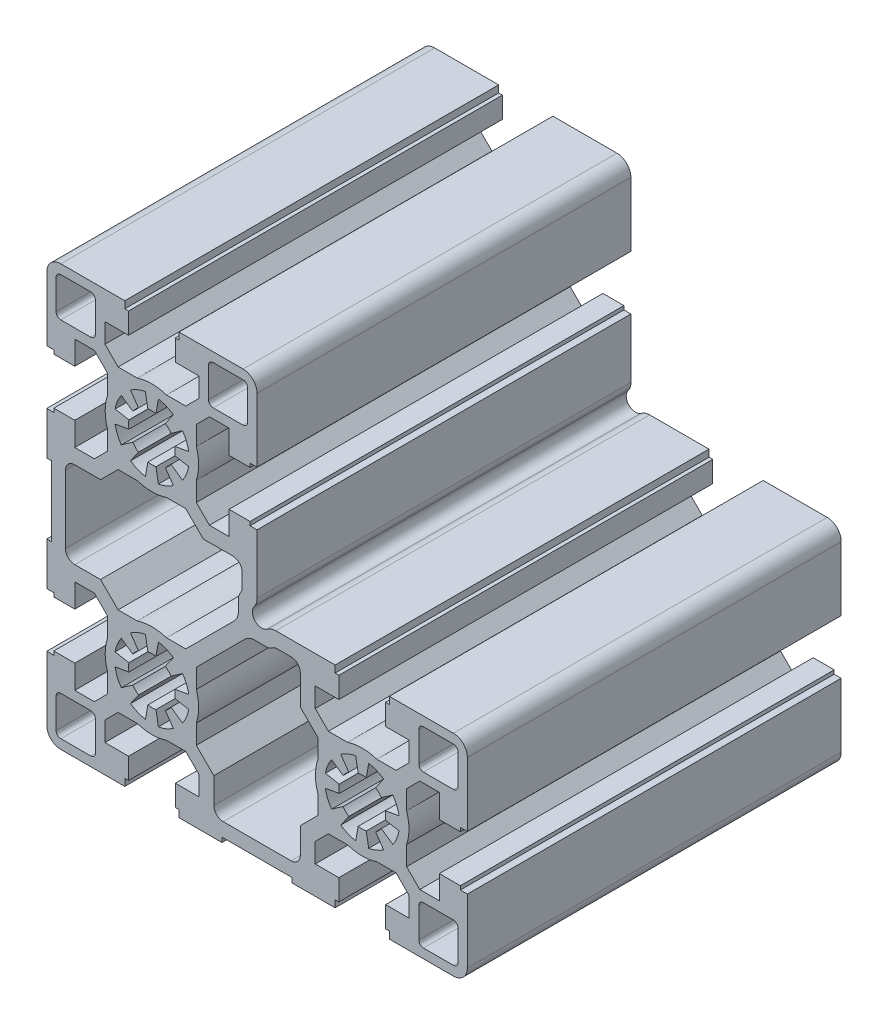
from build123d import *

# Parameters (mm, degrees)
EXTRUDE1_DEPTH = 80


with BuildPart() as part:
    # Sketch1 → Extrude1 (new body)
    with BuildSketch(Plane.XY):
        with BuildLine():
            Line((-81.826623631, 61.217840376), (-68.126623631, 61.217840376))
            Line((-68.126623631, 61.217840376), (-68.126623631, 59.717840379))
            Line((-68.126623631, 59.717840379), (-67.32662363, 59.717840379))
            Line((-67.32662363, 59.717840379), (-67.32662363, 55.217840379))
            Line((-67.32662363, 55.217840379), (-72.37662363, 55.217840379))
            Line((-72.37662363, 55.217840379), (-72.37662363, 51.030582079))
            Line((-72.37662363, 51.030582079), (-69.56388193, 48.217840379))
            Line((-69.56388193, 48.217840379), (-65.44912263, 48.217840379))
            ThreePointArc((-65.44912263, 48.217840379), (-62.32662363, 48.717840379), (-59.20412463, 48.217840379))
            Line((-59.20412463, 48.217840379), (-55.08936533, 48.217840379))
            Line((-55.08936533, 48.217840379), (-52.27662363, 51.030582079))
            Line((-52.27662363, 51.030582079), (-52.27662363, 55.217840379))
            Line((-52.27662363, 55.217840379), (-57.326623631, 55.217840379))
            Line((-57.326623631, 55.217840379), (-57.326623631, 59.717840379))
            Line((-57.326623631, 59.717840379), (-56.526623631, 59.717840379))
            Line((-56.526623631, 59.717840379), (-56.526623631, 61.217840376))
            Line((-56.526623631, 61.217840376), (-42.826623631, 61.217840376))
            ThreePointArc((-42.826623631, 61.217840376), (-40.705303287, 60.339160719), (-39.826623631, 58.217840376))
            Line((-39.826623631, 58.217840376), (-39.826623631, 44.517840379))
            Line((-39.826623631, 44.517840379), (-41.32662363, 44.517840379))
            Line((-41.32662363, 44.517840379), (-41.32662363, 43.717840379))
            Line((-41.32662363, 43.717840379), (-45.82662363, 43.717840379))
            Line((-45.82662363, 43.717840379), (-45.82662363, 48.767840379))
            Line((-45.82662363, 48.767840379), (-50.01388193, 48.767840379))
            Line((-50.01388193, 48.767840379), (-52.82662363, 45.955098679))
            Line((-52.82662363, 45.955098679), (-52.82662363, 41.840339379))
            ThreePointArc((-52.82662363, 41.840339379), (-52.326623629, 38.717840379), (-52.82662363, 35.595341379))
            Line((-52.82662363, 35.595341379), (-52.82662363, 31.480582079))
            Line((-52.82662363, 31.480582079), (-50.01388193, 28.667840379))
            Line((-50.01388193, 28.667840379), (-45.82662363, 28.667840379))
            Line((-45.82662363, 28.667840379), (-45.82662363, 33.717840379))
            Line((-45.82662363, 33.717840379), (-41.32662363, 33.717840379))
            Line((-41.32662363, 33.717840379), (-41.32662363, 32.917840379))
            Line((-41.32662363, 32.917840379), (-39.82662363, 32.917840379))
            Line((-39.82662363, 32.917840379), (-39.82662363, 20.221143989))
            ThreePointArc((-39.82662363, 20.221143989), (-39.982163304, 19.267705236), (-40.432653933, 18.413131519))
            ThreePointArc((-40.432653933, 18.413131519), (-40.250887698, 15.793576309), (-37.631332489, 15.611810073))
            ThreePointArc((-37.631332489, 15.611810073), (-36.776758772, 16.062300701), (-35.823320021, 16.217840375))
            Line((-35.823320021, 16.217840375), (-23.126623631, 16.217840375))
            Line((-23.126623631, 16.217840375), (-23.126623631, 14.717840372))
            Line((-23.126623631, 14.717840372), (-22.326623631, 14.717840372))
            Line((-22.326623631, 14.717840372), (-22.326623631, 10.217840395))
            Line((-22.326623631, 10.217840395), (-27.376623631, 10.217840395))
            Line((-27.376623631, 10.217840395), (-27.376623631, 6.030582095))
            Line((-27.376623631, 6.030582095), (-24.563881931, 3.217840395))
            Line((-24.563881931, 3.217840395), (-20.449122631, 3.217840395))
            ThreePointArc((-20.449122631, 3.217840395), (-17.326623631, 3.717840396), (-14.204124631, 3.217840395))
            Line((-14.204124631, 3.217840395), (-10.089365331, 3.217840395))
            Line((-10.089365331, 3.217840395), (-7.276623631, 6.030582095))
            Line((-7.276623631, 6.030582095), (-7.276623631, 10.217840376))
            Line((-7.276623631, 10.217840376), (-12.326623631, 10.217840376))
            Line((-12.326623631, 10.217840376), (-12.326623631, 14.717840376))
            Line((-12.326623631, 14.717840376), (-11.526623631, 14.717840376))
            Line((-11.526623631, 14.717840376), (-11.526623631, 16.217840376))
            Line((-11.526623631, 16.217840376), (2.173376369, 16.217840376))
            ThreePointArc((2.173376369, 16.217840376), (4.294696713, 15.339160719), (5.173376369, 13.217840376))
            Line((5.173376369, 13.217840376), (5.173376369, -0.482159605))
            Line((5.173376369, -0.482159605), (3.673376369, -0.482159605))
            Line((3.673376369, -0.482159605), (3.673376369, -1.282159605))
            Line((3.673376369, -1.282159605), (-0.826623631, -1.282159605))
            Line((-0.826623631, -1.282159605), (-0.826623631, 3.767840395))
            Line((-0.826623631, 3.767840395), (-5.013881931, 3.767840395))
            Line((-5.013881931, 3.767840395), (-7.826623631, 0.955098695))
            Line((-7.826623631, 0.955098695), (-7.826623631, -3.159660605))
            ThreePointArc((-7.826623631, -3.159660605), (-7.326623631, -6.282159605), (-7.826623631, -9.404658605))
            Line((-7.826623631, -9.404658605), (-7.826623631, -13.519417905))
            Line((-7.826623631, -13.519417905), (-5.013881931, -16.332159605))
            Line((-5.013881931, -16.332159605), (-0.826623631, -16.332159605))
            Line((-0.826623631, -16.332159605), (-0.826623631, -11.282159605))
            Line((-0.826623631, -11.282159605), (3.673376369, -11.282159605))
            Line((3.673376369, -11.282159605), (3.673376369, -12.082159605))
            Line((3.673376369, -12.082159605), (5.173376369, -12.082159605))
            Line((5.173376369, -12.082159605), (5.173376369, -25.782159624))
            ThreePointArc((5.173376369, -25.782159624), (4.294696713, -27.903479968), (2.173376369, -28.782159624))
            Line((2.173376369, -28.782159624), (-11.526623631, -28.782159624))
            Line((-11.526623631, -28.782159624), (-11.526623631, -27.282159624))
            Line((-11.526623631, -27.282159624), (-12.326623631, -27.282159624))
            Line((-12.326623631, -27.282159624), (-12.326623631, -22.782159624))
            Line((-12.326623631, -22.782159624), (-7.276623631, -22.782159624))
            Line((-7.276623631, -22.782159624), (-7.276623631, -18.594901305))
            Line((-7.276623631, -18.594901305), (-10.089365331, -15.782159605))
            Line((-10.089365331, -15.782159605), (-14.204124631, -15.782159605))
            ThreePointArc((-14.204124631, -15.782159605), (-17.326623631, -16.282159605), (-20.449122631, -15.782159605))
            Line((-20.449122631, -15.782159605), (-24.563881931, -15.782159605))
            Line((-24.563881931, -15.782159605), (-27.376623631, -18.594901305))
            Line((-27.376623631, -18.594901305), (-27.376623631, -22.782159605))
            Line((-27.376623631, -22.782159605), (-22.32662363, -22.782159605))
            Line((-22.32662363, -22.782159605), (-22.32662363, -27.282159627))
            Line((-22.32662363, -27.282159627), (-23.12662363, -27.282159627))
            Line((-23.12662363, -27.282159627), (-23.12662363, -28.782159627))
            Line((-23.12662363, -28.782159627), (-32.32662363, -28.782159627))
            Line((-32.32662363, -28.782159627), (-32.32662363, -27.782159627))
            Line((-32.32662363, -27.782159627), (-47.32662363, -27.782159627))
            Line((-47.32662363, -27.782159627), (-47.32662363, -28.782159627))
            Line((-47.32662363, -28.782159627), (-56.52662363, -28.782159627))
            Line((-56.52662363, -28.782159627), (-56.52662363, -27.282159627))
            Line((-56.52662363, -27.282159627), (-57.32662363, -27.282159627))
            Line((-57.32662363, -27.282159627), (-57.32662363, -22.782159627))
            Line((-57.32662363, -22.782159627), (-52.27662363, -22.782159627))
            Line((-52.27662363, -22.782159627), (-52.27662363, -18.594901327))
            Line((-52.27662363, -18.594901327), (-55.08936533, -15.782159627))
            Line((-55.08936533, -15.782159627), (-59.20412463, -15.782159627))
            ThreePointArc((-59.20412463, -15.782159627), (-62.32662363, -16.282159628), (-65.44912263, -15.782159627))
            Line((-65.44912263, -15.782159627), (-69.56388193, -15.782159627))
            Line((-69.56388193, -15.782159627), (-72.37662363, -18.594901327))
            Line((-72.37662363, -18.594901327), (-72.37662363, -22.782159627))
            Line((-72.37662363, -22.782159627), (-67.326623631, -22.782159627))
            Line((-67.326623631, -22.782159627), (-67.326623631, -27.282159624))
            Line((-67.326623631, -27.282159624), (-68.126623631, -27.282159624))
            Line((-68.126623631, -27.282159624), (-68.126623631, -28.782159624))
            Line((-68.126623631, -28.782159624), (-81.826623631, -28.782159624))
            ThreePointArc((-81.826623631, -28.782159624), (-83.947943974, -27.903479968), (-84.826623631, -25.782159624))
            Line((-84.826623631, -25.782159624), (-84.826623631, -12.082159624))
            Line((-84.826623631, -12.082159624), (-83.326623631, -12.082159624))
            Line((-83.326623631, -12.082159624), (-83.326623631, -11.282159624))
            Line((-83.326623631, -11.282159624), (-78.82662363, -11.282159624))
            Line((-78.82662363, -11.282159624), (-78.82662363, -16.332159627))
            Line((-78.82662363, -16.332159627), (-74.63936533, -16.332159627))
            Line((-74.63936533, -16.332159627), (-71.82662363, -13.519417927))
            Line((-71.82662363, -13.519417927), (-71.82662363, -9.404658627))
            ThreePointArc((-71.82662363, -9.404658627), (-72.32662363, -6.282159627), (-71.82662363, -3.159660627))
            Line((-71.82662363, -3.159660627), (-71.82662363, 0.955098673))
            Line((-71.82662363, 0.955098673), (-74.63936533, 3.767840373))
            Line((-74.63936533, 3.767840373), (-78.82662363, 3.767840373))
            Line((-78.82662363, 3.767840373), (-78.82662363, -1.282159627))
            Line((-78.82662363, -1.282159627), (-83.32662363, -1.282159627))
            Line((-83.32662363, -1.282159627), (-83.32662363, -0.482159627))
            Line((-83.32662363, -0.482159627), (-84.82662363, -0.482159627))
            Line((-84.82662363, -0.482159627), (-84.82662363, 8.717840373))
            Line((-84.82662363, 8.717840373), (-83.82662363, 8.717840373))
            Line((-83.82662363, 8.717840373), (-83.82662363, 23.717840373))
            Line((-83.82662363, 23.717840373), (-84.82662363, 23.717840373))
            Line((-84.82662363, 23.717840373), (-84.82662363, 32.917840373))
            Line((-84.82662363, 32.917840373), (-83.32662363, 32.917840373))
            Line((-83.32662363, 32.917840373), (-83.32662363, 33.717840373))
            Line((-83.32662363, 33.717840373), (-78.82662363, 33.717840373))
            Line((-78.82662363, 33.717840373), (-78.82662363, 28.667840379))
            Line((-78.82662363, 28.667840379), (-74.63936533, 28.667840379))
            Line((-74.63936533, 28.667840379), (-71.82662363, 31.480582079))
            Line((-71.82662363, 31.480582079), (-71.82662363, 35.595341379))
            ThreePointArc((-71.82662363, 35.595341379), (-72.32662363, 38.717840379), (-71.82662363, 41.840339379))
            Line((-71.82662363, 41.840339379), (-71.82662363, 45.955098679))
            Line((-71.82662363, 45.955098679), (-74.63936533, 48.767840379))
            Line((-74.63936533, 48.767840379), (-78.826623631, 48.767840379))
            Line((-78.826623631, 48.767840379), (-78.826623631, 43.717840376))
            Line((-78.826623631, 43.717840376), (-83.326623631, 43.717840376))
            Line((-83.326623631, 43.717840376), (-83.326623631, 44.517840376))
            Line((-83.326623631, 44.517840376), (-84.826623631, 44.517840376))
            Line((-84.826623631, 44.517840376), (-84.826623631, 58.217840376))
            ThreePointArc((-84.826623631, 58.217840376), (-83.947943974, 60.339160719), (-81.826623631, 61.217840376))
        make_face()
        with BuildLine():
            Line((3.173376369, -19.382159624), (3.173376369, -25.782159624))
            ThreePointArc((3.173376369, -25.782159624), (2.880483151, -26.489266406), (2.173376369, -26.782159624))
            Line((2.173376369, -26.782159624), (-4.226623631, -26.782159624))
            ThreePointArc((-4.226623631, -26.782159624), (-4.933730412, -26.489266406), (-5.226623631, -25.782159624))
            Line((-5.226623631, -25.782159624), (-5.226623631, -19.382159624))
            ThreePointArc((-5.226623631, -19.382159624), (-4.933730412, -18.675052843), (-4.226623631, -18.382159624))
            Line((-4.226623631, -18.382159624), (2.173376369, -18.382159624))
            ThreePointArc((2.173376369, -18.382159624), (2.880483151, -18.675052843), (3.173376369, -19.382159624))
        make_face(mode=Mode.SUBTRACT)
        with BuildLine():
            Line((-36.920667716, 12.481354098), (-36.442965741, 12.754326662))
            ThreePointArc((-36.442965741, 12.754326662), (-35.96402373, 12.95083968), (-35.450687854, 13.017840384))
            Line((-35.450687854, 13.017840384), (-32.577053934, 13.017840384))
            ThreePointArc((-32.577053934, 13.017840384), (-31.162840372, 12.432053946), (-30.577053935, 11.017840384))
            Line((-30.577053935, 11.017840384), (-30.577053935, 4.705528984))
            Line((-30.577053935, 4.705528984), (-26.826623635, 0.955098684))
            Line((-26.826623635, 0.955098684), (-26.826623635, -3.159660616))
            ThreePointArc((-26.826623635, -3.159660616), (-27.326623632, -6.282159618), (-26.826623627, -9.404658618))
            Line((-26.826623627, -9.404658618), (-26.826623627, -13.519417918))
            Line((-26.826623627, -13.519417918), (-30.577053927, -17.269848218))
            Line((-30.577053927, -17.269848218), (-30.577053927, -22.782159618))
            ThreePointArc((-30.577053927, -22.782159618), (-31.162840364, -24.196373181), (-32.577053927, -24.782159618))
            Line((-32.577053927, -24.782159618), (-47.076623627, -24.782159618))
            ThreePointArc((-47.076623627, -24.782159618), (-48.490837189, -24.196373181), (-49.076623627, -22.782159618))
            Line((-49.076623627, -22.782159618), (-49.076623627, -17.269417918))
            Line((-49.076623627, -17.269417918), (-52.826623627, -13.519417918))
            Line((-52.826623627, -13.519417918), (-52.826623627, -9.404658618))
            ThreePointArc((-52.826623627, -9.404658618), (-52.326623629, -6.282159618), (-52.826623633, -3.159660618))
            Line((-52.826623633, -3.159660618), (-52.826623633, 0.955098682))
            Line((-52.826623633, 0.955098682), (-42.442561593, 11.339160722))
            ThreePointArc((-42.442561593, 11.339160722), (-41.469291546, 11.989478975), (-40.321241249, 12.217840376))
            Line((-40.321241249, 12.217840376), (-37.912945604, 12.217840376))
            ThreePointArc((-37.912945604, 12.217840376), (-37.399609728, 12.28484108), (-36.920667716, 12.481354098))
        make_face(mode=Mode.SUBTRACT)
        with BuildLine():
            Line((-18.715809051, 1.596302416), (-18.194864521, -1.358120845))
            ThreePointArc((-18.194864521, -1.358120845), (-17.326623631, -1.282159609), (-16.458382741, -1.358120845))
            Line((-16.458382741, -1.358120845), (-15.937438211, 1.596302415))
            ThreePointArc((-15.937438211, 1.596302415), (-14.265156173, 1.108876651), (-12.738012141, 0.271056745))
            Line((-12.738012141, 0.271056745), (-14.458741451, -2.186399385))
            ThreePointArc((-14.458741451, -2.186399385), (-13.791089727, -2.7466257), (-13.230863411, -3.414277425))
            Line((-13.230863411, -3.414277425), (-10.773407281, -1.693548115))
            ThreePointArc((-10.773407281, -1.693548115), (-9.935587375, -3.220692147), (-9.448161611, -4.892974184))
            Line((-9.448161611, -4.892974184), (-12.402584871, -5.413918715))
            ThreePointArc((-12.402584871, -5.413918715), (-12.326623636, -6.282159605), (-12.402584871, -7.150400495))
            Line((-12.402584871, -7.150400495), (-9.448161611, -7.671345025))
            ThreePointArc((-9.448161611, -7.671345025), (-9.935587375, -9.343627062), (-10.773407281, -10.870771094))
            Line((-10.773407281, -10.870771094), (-13.230863411, -9.150041785))
            ThreePointArc((-13.230863411, -9.150041785), (-13.791089727, -9.817693509), (-14.458741451, -10.377919825))
            Line((-14.458741451, -10.377919825), (-12.738012141, -12.835375955))
            ThreePointArc((-12.738012141, -12.835375955), (-14.265156173, -13.673195861), (-15.937438211, -14.160621625))
            Line((-15.937438211, -14.160621625), (-16.458382741, -11.206198365))
            ThreePointArc((-16.458382741, -11.206198365), (-17.326623631, -11.2821596), (-18.194864521, -11.206198365))
            Line((-18.194864521, -11.206198365), (-18.715809051, -14.160621625))
            ThreePointArc((-18.715809051, -14.160621625), (-20.388091089, -13.67319586), (-21.915235121, -12.835375954))
            Line((-21.915235121, -12.835375954), (-20.194505811, -10.377919825))
            ThreePointArc((-20.194505811, -10.377919825), (-20.862157536, -9.817693509), (-21.422383851, -9.150041785))
            Line((-21.422383851, -9.150041785), (-23.879839981, -10.870771095))
            ThreePointArc((-23.879839981, -10.870771095), (-24.717659887, -9.343627062), (-25.205085652, -7.671345025))
            Line((-25.205085652, -7.671345025), (-22.250662391, -7.150400495))
            ThreePointArc((-22.250662391, -7.150400495), (-22.326623627, -6.282159605), (-22.250662391, -5.413918715))
            Line((-22.250662391, -5.413918715), (-25.205085651, -4.892974185))
            ThreePointArc((-25.205085651, -4.892974185), (-24.717659887, -3.220692147), (-23.879839981, -1.693548115))
            Line((-23.879839981, -1.693548115), (-21.422383851, -3.414277425))
            ThreePointArc((-21.422383851, -3.414277425), (-20.862157536, -2.7466257), (-20.194505811, -2.186399385))
            Line((-20.194505811, -2.186399385), (-21.915235121, 0.271056745))
            ThreePointArc((-21.915235121, 0.271056745), (-20.388091089, 1.108876652), (-18.715809051, 1.596302416))
        make_face(mode=Mode.SUBTRACT)
        with BuildLine():
            Line((-4.226623631, 14.217840376), (2.173376369, 14.217840376))
            ThreePointArc((2.173376369, 14.217840376), (2.880483151, 13.924947157), (3.173376369, 13.217840376))
            Line((3.173376369, 13.217840376), (3.173376369, 6.817840376))
            ThreePointArc((3.173376369, 6.817840376), (2.880483151, 6.110733594), (2.173376369, 5.817840376))
            Line((2.173376369, 5.817840376), (-4.226623631, 5.817840376))
            ThreePointArc((-4.226623631, 5.817840376), (-4.933730412, 6.110733594), (-5.226623631, 6.817840376))
            Line((-5.226623631, 6.817840376), (-5.226623631, 13.217840376))
            ThreePointArc((-5.226623631, 13.217840376), (-4.933730412, 13.924947157), (-4.226623631, 14.217840376))
        make_face(mode=Mode.SUBTRACT)
        with BuildLine():
            Line((-42.826623631, 50.817840376), (-49.226623631, 50.817840376))
            ThreePointArc((-49.226623631, 50.817840376), (-49.933730412, 51.110733594), (-50.226623631, 51.817840376))
            Line((-50.226623631, 51.817840376), (-50.226623631, 58.217840376))
            ThreePointArc((-50.226623631, 58.217840376), (-49.933730412, 58.924947157), (-49.226623631, 59.217840376))
            Line((-49.226623631, 59.217840376), (-42.826623631, 59.217840376))
            ThreePointArc((-42.826623631, 59.217840376), (-42.119516849, 58.924947157), (-41.826623631, 58.217840376))
            Line((-41.826623631, 58.217840376), (-41.826623631, 51.817840376))
            ThreePointArc((-41.826623631, 51.817840376), (-42.119516849, 51.110733594), (-42.826623631, 50.817840376))
        make_face(mode=Mode.SUBTRACT)
        with BuildLine():
            Line((-63.71580905, 46.596302399), (-63.19486452, 43.641879139))
            ThreePointArc((-63.19486452, 43.641879139), (-62.32662363, 43.717840374), (-61.45838274, 43.641879139))
            Line((-61.45838274, 43.641879139), (-60.93743821, 46.596302399))
            ThreePointArc((-60.93743821, 46.596302399), (-59.265156172, 46.108876634), (-57.73801214, 45.271056728))
            Line((-57.73801214, 45.271056728), (-59.45874145, 42.813600599))
            ThreePointArc((-59.45874145, 42.813600599), (-58.791089725, 42.253374283), (-58.23086341, 41.585722559))
            Line((-58.23086341, 41.585722559), (-55.77340728, 43.306451869))
            ThreePointArc((-55.77340728, 43.306451869), (-54.935587374, 41.779307837), (-54.448161609, 40.107025799))
            Line((-54.448161609, 40.107025799), (-57.40258487, 39.586081269))
            ThreePointArc((-57.40258487, 39.586081269), (-57.326623634, 38.717840379), (-57.40258487, 37.849599489))
            Line((-57.40258487, 37.849599489), (-54.44816161, 37.328654959))
            ThreePointArc((-54.44816161, 37.328654959), (-54.935587374, 35.656372921), (-55.77340728, 34.129228889))
            Line((-55.77340728, 34.129228889), (-58.23086341, 35.849958199))
            ThreePointArc((-58.23086341, 35.849958199), (-58.791089725, 35.182306474), (-59.45874145, 34.622080159))
            Line((-59.45874145, 34.622080159), (-57.73801214, 32.164624029))
            ThreePointArc((-57.73801214, 32.164624029), (-59.265156172, 31.326804122), (-60.93743821, 30.839378358))
            Line((-60.93743821, 30.839378358), (-61.45838274, 33.793801619))
            ThreePointArc((-61.45838274, 33.793801619), (-62.32662363, 33.717840383), (-63.19486452, 33.793801619))
            Line((-63.19486452, 33.793801619), (-63.71580905, 30.839378359))
            ThreePointArc((-63.71580905, 30.839378359), (-65.388091088, 31.326804123), (-66.91523512, 32.164624029))
            Line((-66.91523512, 32.164624029), (-65.19450581, 34.622080159))
            ThreePointArc((-65.19450581, 34.622080159), (-65.862157534, 35.182306474), (-66.42238385, 35.849958199))
            Line((-66.42238385, 35.849958199), (-68.87983998, 34.129228889))
            ThreePointArc((-68.87983998, 34.129228889), (-69.717659886, 35.656372921), (-70.20508565, 37.328654959))
            Line((-70.20508565, 37.328654959), (-67.25066239, 37.849599489))
            ThreePointArc((-67.25066239, 37.849599489), (-67.326623625, 38.717840379), (-67.25066239, 39.586081269))
            Line((-67.25066239, 39.586081269), (-70.20508565, 40.107025799))
            ThreePointArc((-70.20508565, 40.107025799), (-69.717659886, 41.779307836), (-68.879839979, 43.306451868))
            Line((-68.879839979, 43.306451868), (-66.42238385, 41.585722559))
            ThreePointArc((-66.42238385, 41.585722559), (-65.862157534, 42.253374283), (-65.19450581, 42.813600599))
            Line((-65.19450581, 42.813600599), (-66.91523512, 45.271056729))
            ThreePointArc((-66.91523512, 45.271056729), (-65.388091088, 46.108876635), (-63.71580905, 46.596302399))
        make_face(mode=Mode.SUBTRACT)
        with BuildLine():
            Line((-44.705303281, 13.60190241), (-55.089365321, 3.21784037))
            Line((-55.089365321, 3.21784037), (-59.204124621, 3.21784037))
            ThreePointArc((-59.204124621, 3.21784037), (-62.32662362, 3.717840373), (-65.449122621, 3.217840376))
            Line((-65.449122621, 3.217840376), (-69.563881921, 3.217840376))
            Line((-69.563881921, 3.217840376), (-73.313881921, 6.967840376))
            Line((-73.313881921, 6.967840376), (-78.826623621, 6.967840376))
            ThreePointArc((-78.826623621, 6.967840376), (-80.240837183, 7.553626813), (-80.826623621, 8.967840376))
            Line((-80.826623621, 8.967840376), (-80.826623621, 23.467410076))
            ThreePointArc((-80.826623621, 23.467410076), (-80.240837183, 24.881623638), (-78.826623621, 25.467410076))
            Line((-78.826623621, 25.467410076), (-73.314312221, 25.467410076))
            Line((-73.314312221, 25.467410076), (-69.563881921, 29.217840376))
            Line((-69.563881921, 29.217840376), (-65.449122621, 29.217840376))
            ThreePointArc((-65.449122621, 29.217840376), (-62.32662362, 28.717840378), (-59.204124621, 29.217840382))
            Line((-59.204124621, 29.217840382), (-55.089365321, 29.217840382))
            Line((-55.089365321, 29.217840382), (-51.338935021, 25.467410082))
            Line((-51.338935021, 25.467410082), (-45.026623621, 25.467410082))
            ThreePointArc((-45.026623621, 25.467410082), (-43.612410058, 24.881623644), (-43.026623621, 23.467410082))
            Line((-43.026623621, 23.467410082), (-43.026623621, 20.593776162))
            ThreePointArc((-43.026623621, 20.593776162), (-43.093624325, 20.080440285), (-43.290137343, 19.601498274))
            Line((-43.290137343, 19.601498274), (-43.563109907, 19.123796299))
            ThreePointArc((-43.563109907, 19.123796299), (-43.759622925, 18.644854281), (-43.826623626, 18.131518399))
            Line((-43.826623626, 18.131518399), (-43.826623626, 15.723222749))
            ThreePointArc((-43.826623626, 15.723222749), (-44.054985028, 14.575172454), (-44.705303281, 13.60190241))
        make_face(mode=Mode.SUBTRACT)
        with BuildLine():
            Line((-63.71580905, 1.596302393), (-63.19486452, -1.358120867))
            ThreePointArc((-63.19486452, -1.358120867), (-62.32662363, -1.282159632), (-61.45838274, -1.358120867))
            Line((-61.45838274, -1.358120867), (-60.93743821, 1.596302393))
            ThreePointArc((-60.93743821, 1.596302393), (-59.265156172, 1.108876629), (-57.73801214, 0.271056722))
            Line((-57.73801214, 0.271056722), (-59.45874145, -2.186399407))
            ThreePointArc((-59.45874145, -2.186399407), (-58.791089725, -2.746625723), (-58.23086341, -3.414277447))
            Line((-58.23086341, -3.414277447), (-55.77340728, -1.693548137))
            ThreePointArc((-55.77340728, -1.693548137), (-54.935587374, -3.220692169), (-54.448161609, -4.892974207))
            Line((-54.448161609, -4.892974207), (-57.40258487, -5.413918737))
            ThreePointArc((-57.40258487, -5.413918737), (-57.326623634, -6.282159627), (-57.40258487, -7.150400517))
            Line((-57.40258487, -7.150400517), (-54.44816161, -7.671345047))
            ThreePointArc((-54.44816161, -7.671345047), (-54.935587374, -9.343627085), (-55.77340728, -10.870771117))
            Line((-55.77340728, -10.870771117), (-58.23086341, -9.150041807))
            ThreePointArc((-58.23086341, -9.150041807), (-58.791089725, -9.817693532), (-59.45874145, -10.377919847))
            Line((-59.45874145, -10.377919847), (-57.73801214, -12.835375977))
            ThreePointArc((-57.73801214, -12.835375977), (-59.265156172, -13.673195884), (-60.93743821, -14.160621648))
            Line((-60.93743821, -14.160621648), (-61.45838274, -11.206198387))
            ThreePointArc((-61.45838274, -11.206198387), (-62.32662363, -11.282159623), (-63.19486452, -11.206198387))
            Line((-63.19486452, -11.206198387), (-63.71580905, -14.160621647))
            ThreePointArc((-63.71580905, -14.160621647), (-65.388091088, -13.673195883), (-66.91523512, -12.835375977))
            Line((-66.91523512, -12.835375977), (-65.19450581, -10.377919847))
            ThreePointArc((-65.19450581, -10.377919847), (-65.862157534, -9.817693532), (-66.42238385, -9.150041807))
            Line((-66.42238385, -9.150041807), (-68.87983998, -10.870771117))
            ThreePointArc((-68.87983998, -10.870771117), (-69.717659886, -9.343627085), (-70.20508565, -7.671345047))
            Line((-70.20508565, -7.671345047), (-67.25066239, -7.150400517))
            ThreePointArc((-67.25066239, -7.150400517), (-67.326623625, -6.282159627), (-67.25066239, -5.413918737))
            Line((-67.25066239, -5.413918737), (-70.20508565, -4.892974207))
            ThreePointArc((-70.20508565, -4.892974207), (-69.717659886, -3.22069217), (-68.879839979, -1.693548138))
            Line((-68.879839979, -1.693548138), (-66.42238385, -3.414277447))
            ThreePointArc((-66.42238385, -3.414277447), (-65.862157534, -2.746625723), (-65.19450581, -2.186399407))
            Line((-65.19450581, -2.186399407), (-66.91523512, 0.271056723))
            ThreePointArc((-66.91523512, 0.271056723), (-65.388091088, 1.108876629), (-63.71580905, 1.596302393))
        make_face(mode=Mode.SUBTRACT)
        with BuildLine():
            Line((-82.826623631, 51.817840376), (-82.826623631, 58.217840376))
            ThreePointArc((-82.826623631, 58.217840376), (-82.533730412, 58.924947157), (-81.826623631, 59.217840376))
            Line((-81.826623631, 59.217840376), (-75.426623631, 59.217840376))
            ThreePointArc((-75.426623631, 59.217840376), (-74.719516849, 58.924947157), (-74.426623631, 58.217840376))
            Line((-74.426623631, 58.217840376), (-74.426623631, 51.817840376))
            ThreePointArc((-74.426623631, 51.817840376), (-74.719516849, 51.110733594), (-75.426623631, 50.817840376))
            Line((-75.426623631, 50.817840376), (-81.826623631, 50.817840376))
            ThreePointArc((-81.826623631, 50.817840376), (-82.533730412, 51.110733594), (-82.826623631, 51.817840376))
        make_face(mode=Mode.SUBTRACT)
        with BuildLine():
            Line((-75.426623631, -26.782159624), (-81.826623631, -26.782159624))
            ThreePointArc((-81.826623631, -26.782159624), (-82.533730412, -26.489266406), (-82.826623631, -25.782159624))
            Line((-82.826623631, -25.782159624), (-82.826623631, -19.382159624))
            ThreePointArc((-82.826623631, -19.382159624), (-82.533730412, -18.675052843), (-81.826623631, -18.382159624))
            Line((-81.826623631, -18.382159624), (-75.426623631, -18.382159624))
            ThreePointArc((-75.426623631, -18.382159624), (-74.719516849, -18.675052843), (-74.426623631, -19.382159624))
            Line((-74.426623631, -19.382159624), (-74.426623631, -25.782159624))
            ThreePointArc((-74.426623631, -25.782159624), (-74.719516849, -26.489266406), (-75.426623631, -26.782159624))
        make_face(mode=Mode.SUBTRACT)
    extrude(amount=-EXTRUDE1_DEPTH)


solid = part.part
